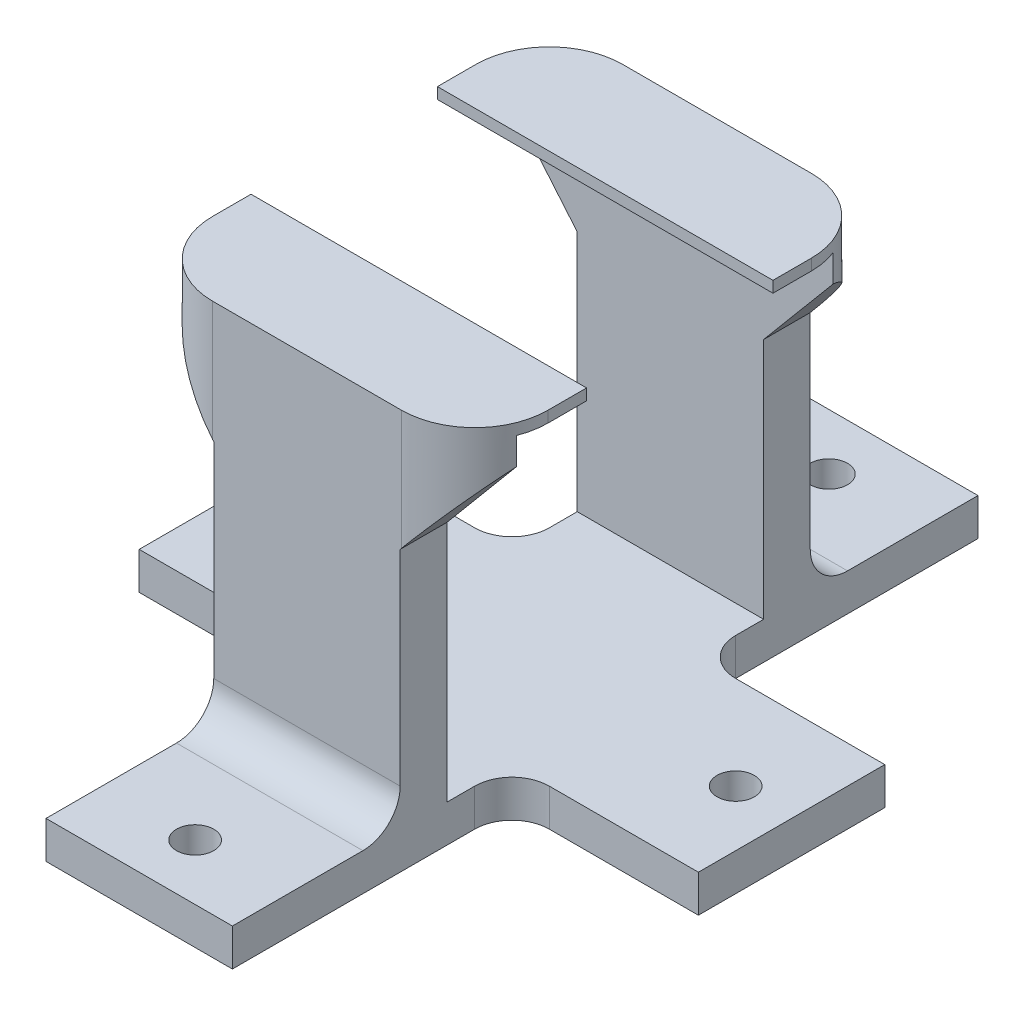
from build123d import *

# Parameters (mm, degrees)
BASE_DEPTH                = 25.4
BOSS_EXTRUDE1_DEPTH       = 6.35
BOSS_EXTRUDE2_DEPTH       = 6.35
SKETCH7_W                 = 45.72
SKETCH7_H                 = 1.524
BOSS_EXTRUDE3_DEPTH       = 8.89
SKETCH3_W                 = 25.4
SKETCH3_H                 = 5.08
FRONT_SCREW_SUPPORT_DEPTH = 25.4
SKETCH4_R                 = 2.54
CUT_EXTRUDE1_DEPTH        = 5.08
FILLET3_R                 = 10
FILLET4_R                 = 5.08


with BuildPart() as part:
    # Sketch1 → Base (new body)
    with BuildSketch(Plane(origin=(0, 0, 0), x_dir=(0, 0, -1), z_dir=(1, 0, 0))):
        Polygon((0, 0), (0, 5.08), (22.86, 5.08), (22.86, 52.07), (29.21, 52.07), (29.21, 5.08), (72.39, 5.08), (72.39, 52.07), (78.74, 52.07), (78.74, 5.08), (101.6, 5.08), (101.6, 0), align=None)
    extrude(amount=BASE_DEPTH)

    # Sketch5 → Boss-Extrude1 (add)
    with BuildSketch(Plane(origin=(0, 0, -78.74), x_dir=(-1, 0, 0), z_dir=(0, 0, -1))):
        Polygon((-35.56, 52.07), (-35.56, 50.208216501), (-25.4, 38.1), (-25.4, 52.07), (0, 52.07), (0, 38.1), (10.16, 50.208216501), (10.16, 52.07), (10.16, 54.61), (-35.56, 54.61), align=None)
    extrude(amount=-BOSS_EXTRUDE1_DEPTH)

    # Sketch6 → Boss-Extrude2 (add)
    with BuildSketch(Plane.XY.offset(-22.86)):
        Polygon((0, 52.07), (0, 38.1), (-10.16, 50.208216501), (-10.16, 54.61), (35.56, 54.61), (35.56, 50.208216501), (25.4, 38.1), (25.4, 52.07), align=None)
    extrude(amount=-BOSS_EXTRUDE2_DEPTH)

    # Sketch7 → Boss-Extrude3 (add)
    with BuildSketch(Plane.XY.offset(-72.39)):
        with Locations((12.7, 53.848)):
            Rectangle(SKETCH7_W, SKETCH7_H)
    boss_extrude3 = extrude(amount=BOSS_EXTRUDE3_DEPTH)

    # Mirror19: Boss-Extrude3 across plane
    add(boss_extrude3.mirror(Plane.XY.offset(-50.8)))

    # Sketch3 → Front Screw Support (add)
    with BuildSketch(Plane(origin=(25.4, 0, 0), x_dir=(0, 0, -1), z_dir=(1, 0, 0))):
        with Locations((50.8, 2.54)):
            Rectangle(SKETCH3_W, SKETCH3_H)
    front_screw_support = extrude(amount=FRONT_SCREW_SUPPORT_DEPTH)

    # Mirror3: Front Screw Support across plane
    add(front_screw_support.mirror(Plane(origin=(12.7, 0, 0), x_dir=(0, 0, 1), z_dir=(1, 0, 0))))

    # Sketch4 → Cut-Extrude1 (cut)
    with BuildSketch(Plane(origin=(0, 5.08, 0), x_dir=(1, 0, 0), z_dir=(0, 1, 0))):
        with Locations((-17.78, 50.8)):
            Circle(SKETCH4_R)
        with Locations((43.18, 50.8)):
            Circle(SKETCH4_R)
        with Locations((12.7, 93.98)):
            Circle(SKETCH4_R)
        with Locations((12.7, 7.62)):
            Circle(SKETCH4_R)
    extrude(amount=-CUT_EXTRUDE1_DEPTH, mode=Mode.SUBTRACT)

    # Fillet3
    fillet3_edges = [part.edges().sort_by_distance(p)[0] for p in [
        (35.56, 52.40910825, -78.74),
        (-10.16, 52.40910825, -78.74),
        (-10.16, 52.40910825, -22.86),
        (35.56, 52.40910825, -22.86),
    ]]
    fillet(fillet3_edges, radius=FILLET3_R)

    # Fillet4
    fillet4_edges = [part.edges().sort_by_distance(p)[0] for p in [
        (25.4, 2.54, -63.5),
        (25.4, 2.54, -38.1),
        (0, 2.54, -63.5),
        (0, 2.54, -38.1),
        (12.7, 5.08, -22.86),
        (12.7, 5.08, -78.74),
    ]]
    fillet(fillet4_edges, radius=FILLET4_R)


solid = part.part
